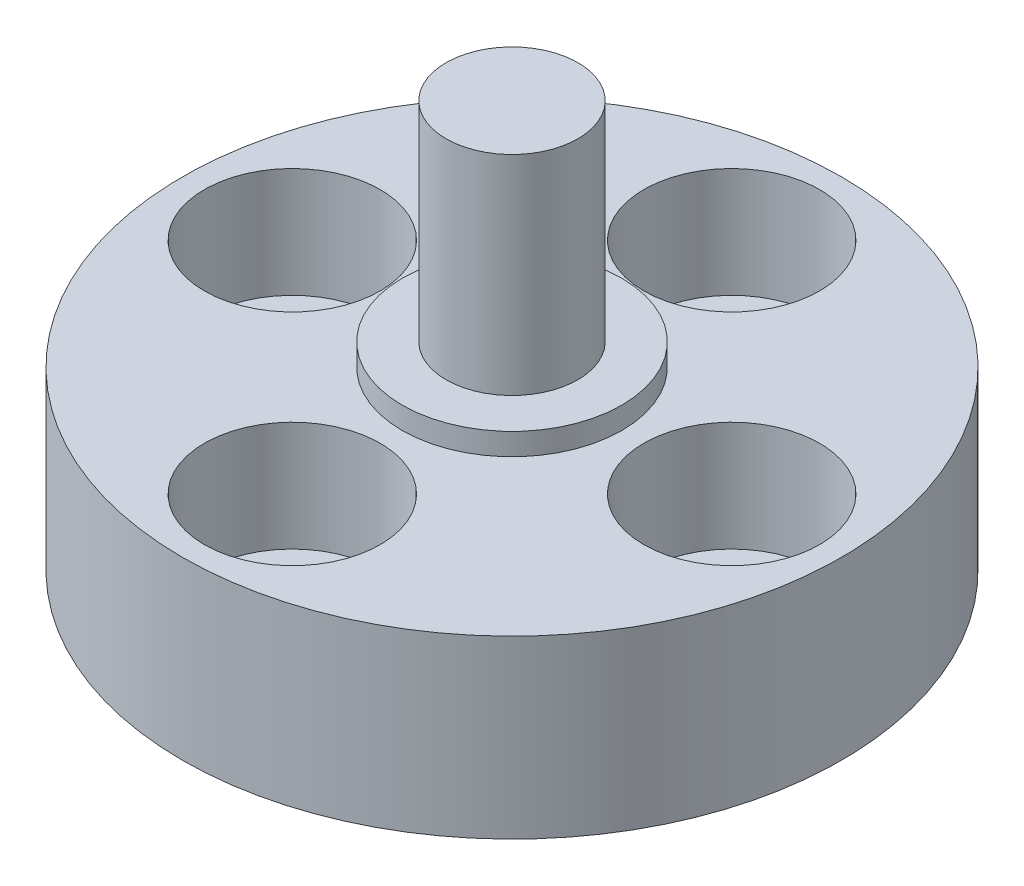
from build123d import *

# Parameters (mm, degrees)
SKETCH1_R           = 15
BOSS_EXTRUDE1_DEPTH = 8
SKETCH2_R           = 5
BOSS_EXTRUDE2_DEPTH = 1
SKETCH3_R           = 3
BOSS_EXTRUDE3_DEPTH = 9.5
HOLE1_D             = 4
HOLE1_CBORE_D       = 8
HOLE1_CBORE_DEPTH   = 5


with BuildPart() as part:
    # Sketch1 → Boss-Extrude1 (new body)
    with BuildSketch(Plane(origin=(0, 0, 0), x_dir=(1, 0, 0), z_dir=(0, 1, 0))):
        Circle(SKETCH1_R)
    extrude(amount=BOSS_EXTRUDE1_DEPTH)

    # Sketch2 → Boss-Extrude2 (add)
    with BuildSketch(Plane(origin=(0, 8, 0), x_dir=(1, 0, 0), z_dir=(0, 1, 0))):
        Circle(SKETCH2_R)
    extrude(amount=BOSS_EXTRUDE2_DEPTH)

    # Sketch3 → Boss-Extrude3 (add)
    with BuildSketch(Plane(origin=(0, 9, 0), x_dir=(1, 0, 0), z_dir=(0, 1, 0))):
        Circle(SKETCH3_R)
    extrude(amount=BOSS_EXTRUDE3_DEPTH)

    # Hole1 (through all)
    with Locations(Plane(origin=(0, 8, 0), x_dir=(1, 0, 0), z_dir=(0, 1, 0))):
        with Locations((-10, 0), (0, 10), (10, 0), (0, -10)):
            CounterBoreHole(HOLE1_D / 2, HOLE1_CBORE_D / 2, HOLE1_CBORE_DEPTH)


solid = part.part
